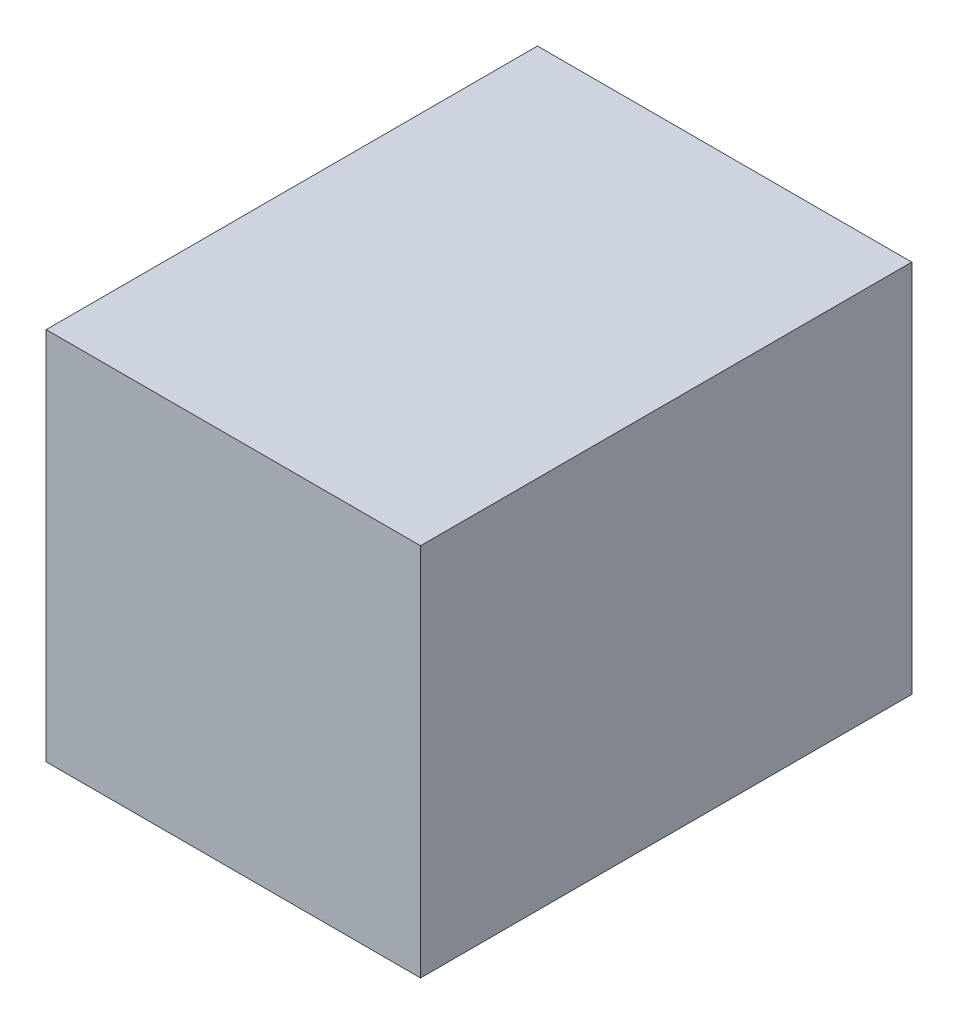
from build123d import *

# Parameters (mm, degrees)
SKETCH1_W           = 762
SKETCH1_H           = 762
BOSS_EXTRUDE1_DEPTH = 1000


with BuildPart() as part:
    # Sketch1 → Boss-Extrude1 (new body)
    with BuildSketch(Plane.XY):
        Rectangle(SKETCH1_W, SKETCH1_H)
    extrude(amount=BOSS_EXTRUDE1_DEPTH)


solid = part.part
